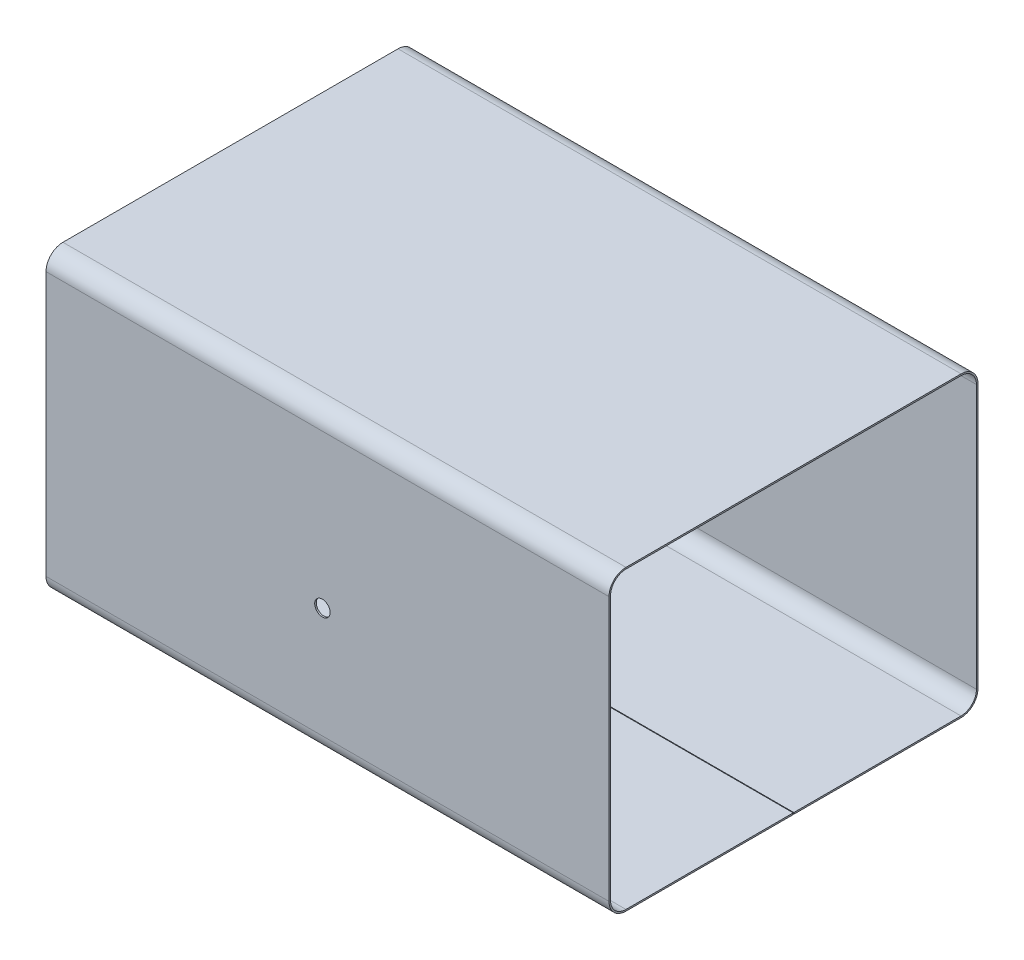
from build123d import *

# Parameters (mm, degrees)
EXTRUDE_THIN1_DEPTH = 182.7
SKETCH2_R           = 2.5
CUT_EXTRUDE1_DEPTH  = 120.738328299


with BuildPart() as part:
    # Sketch1 → Extrude-Thin1 (new body)
    with BuildSketch(Plane(origin=(0, 0, 0), x_dir=(0, 0, -1), z_dir=(1, 0, 0))):
        with BuildLine():
            Line((0.1, -47.818646587), (54.36916415, -47.818646587))
            ThreePointArc((54.36916415, -47.818646587), (57.904698056, -46.354180493), (59.36916415, -42.818646587))
            Line((59.36916415, -42.818646587), (59.36916415, 42.818646587))
            ThreePointArc((59.36916415, 42.818646587), (57.904698056, 46.354180493), (54.36916415, 47.818646587))
            Line((54.36916415, 47.818646587), (-54.36916415, 47.818646587))
            ThreePointArc((-54.36916415, 47.818646587), (-57.904698056, 46.354180493), (-59.36916415, 42.818646587))
            Line((-59.36916415, 42.818646587), (-59.36916415, -42.818646587))
            ThreePointArc((-59.36916415, -42.818646587), (-57.904698056, -46.354180493), (-54.36916415, -47.818646587))
            Line((-54.36916415, -47.818646587), (-0.1, -47.818646587))
            Line((-0.1, -47.818646587), (-0.1, -48.318646587))
            Line((-0.1, -48.318646587), (-54.36916415, -48.318646587))
            ThreePointArc((-54.36916415, -48.318646587), (-58.258251446, -46.707733884), (-59.86916415, -42.818646587))
            Line((-59.86916415, -42.818646587), (-59.86916415, 42.818646587))
            ThreePointArc((-59.86916415, 42.818646587), (-58.258251446, 46.707733884), (-54.36916415, 48.318646587))
            Line((-54.36916415, 48.318646587), (54.36916415, 48.318646587))
            ThreePointArc((54.36916415, 48.318646587), (58.258251446, 46.707733884), (59.86916415, 42.818646587))
            Line((59.86916415, 42.818646587), (59.86916415, -42.818646587))
            ThreePointArc((59.86916415, -42.818646587), (58.258251446, -46.707733884), (54.36916415, -48.318646587))
            Line((54.36916415, -48.318646587), (0.1, -48.318646587))
            Line((0.1, -48.318646587), (0.1, -47.818646587))
        make_face()
    extrude(amount=-EXTRUDE_THIN1_DEPTH)

    # Sketch2 → Cut-Extrude1 (cut, through all)
    with BuildSketch(Plane.XY.offset(59.86916415)):
        with Locations((-93.006946801, -6.886778216)):
            Circle(SKETCH2_R)
    extrude(amount=-CUT_EXTRUDE1_DEPTH, mode=Mode.SUBTRACT)


solid = part.part
